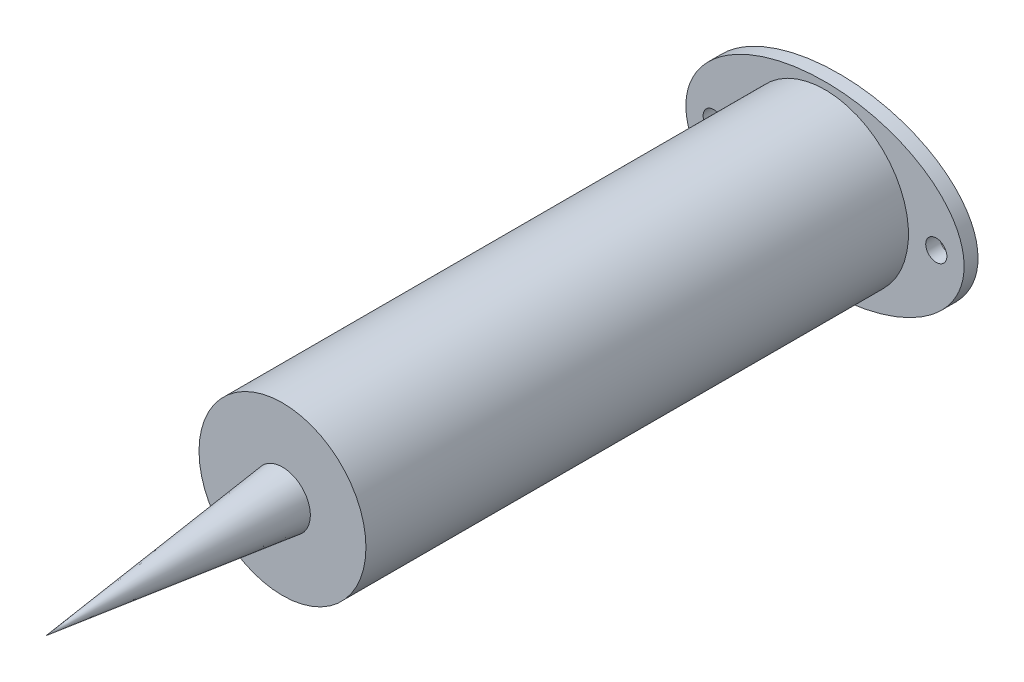
from build123d import *

# Parameters (mm, degrees)
SKETCH1_R           = 19.05
SKETCH1_R_2         = 17.4625
BOSS_EXTRUDE1_DEPTH = 123.825
SKETCH2_RX          = 31.75
SKETCH2_RY          = 20.6375
SKETCH2_R           = 17.4625
SKETCH2_R_2         = 2.413
BOSS_EXTRUDE2_DEPTH = 3.175
SKETCH3_R           = 17.4625
BOSS_EXTRUDE3_DEPTH = 4.953


with BuildPart() as part:
    # Sketch1 → Boss-Extrude1 (new body)
    with BuildSketch(Plane.XY):
        Circle(SKETCH1_R)
        Circle(SKETCH1_R_2, mode=Mode.SUBTRACT)
    extrude(amount=BOSS_EXTRUDE1_DEPTH)

    # Sketch2 → Boss-Extrude2 (add)
    with BuildSketch(Plane(origin=(0, 0, 0), x_dir=(-1, 0, 0), z_dir=(0, 0, -1))):
        with Locations((0, 0)):
            Ellipse(SKETCH2_RX, SKETCH2_RY)
        Circle(SKETCH2_R, mode=Mode.SUBTRACT)
        with Locations((25.4, 0)):
            Circle(SKETCH2_R_2, mode=Mode.SUBTRACT)
        with Locations((-25.4, 0)):
            Circle(SKETCH2_R_2, mode=Mode.SUBTRACT)
    extrude(amount=BOSS_EXTRUDE2_DEPTH)

    # Sketch3 → Boss-Extrude3 (add)
    with BuildSketch(Plane.XY.offset(123.825)):
        Circle(SKETCH3_R)
    extrude(amount=-BOSS_EXTRUDE3_DEPTH)

    # Sketch4 → Revolve1 (revolve)
    with BuildSketch(Plane(origin=(0, 0, 0), x_dir=(1, 0, 0), z_dir=(0, 1, 0))):
        Polygon((0, -123.825), (0, -177.8), (6.35, -123.825), align=None)
    revolve(axis=Axis((0, 0, 123.825), (0, 0, 1)))


solid = part.part
